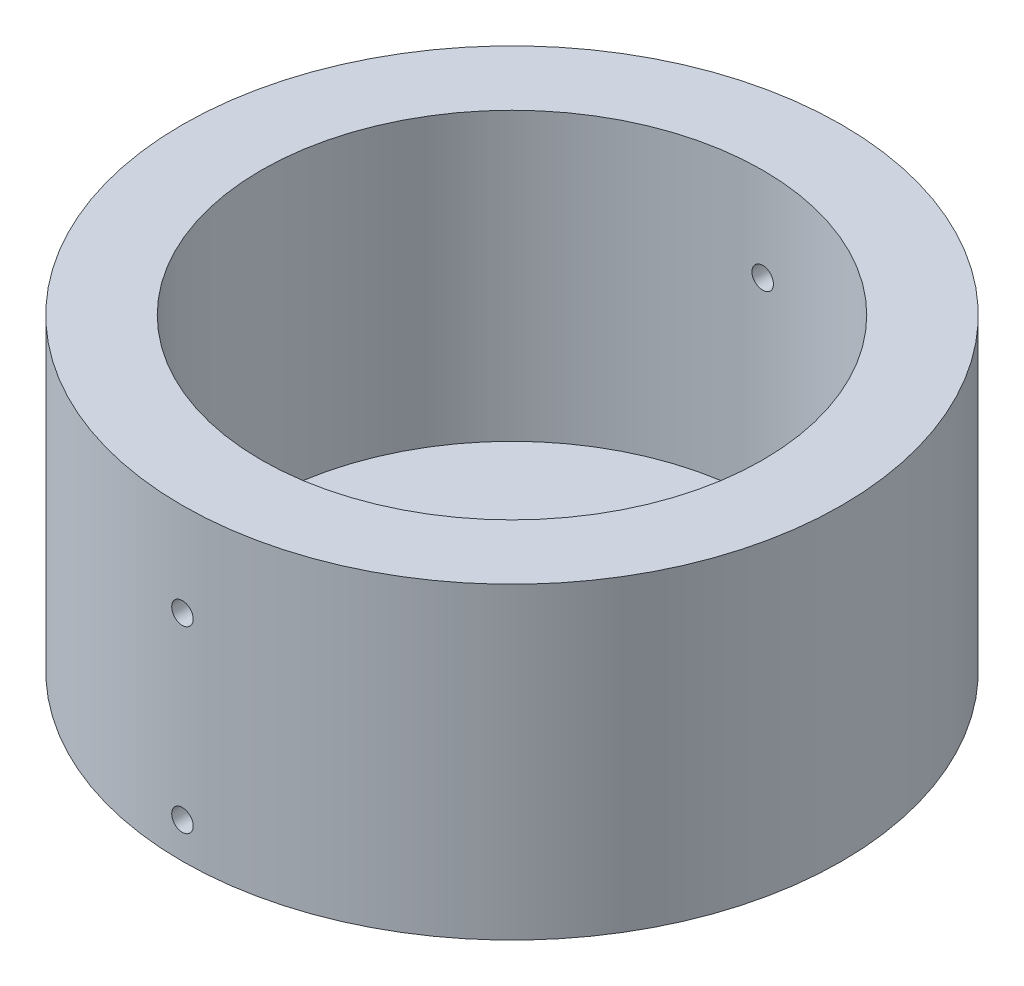
from build123d import *

# Parameters (mm, degrees)
SKETCH1_R               = 46
SKETCH1_R_2             = 3
SKETCH1_R_3             = 1.4
BOSS_EXTRUDE1_DEPTH     = 3
SKETCH6_R               = 1
CUT_EXTRUDE2_DEPTH      = 3
SKETCH7_R               = 46
SKETCH7_R_2             = 35
BOSS_EXTRUDE2_DEPTH     = 40
SKETCH8_R               = 1.5
CUT_EXTRUDE3_DEPTH      = 108
SKETCH9_R               = 1.5
CUT_EXTRUDE4_DEPTH      = 47.00000011
CUT_EXTRUDE4_DEPTH_BACK = 47.00000011


with BuildPart() as part:
    # Sketch1 → Boss-Extrude1 (new body)
    with BuildSketch(Plane(origin=(0, 0, 0), x_dir=(1, 0, 0), z_dir=(0, 1, 0))):
        Circle(SKETCH1_R)
        Circle(SKETCH1_R_2, mode=Mode.SUBTRACT)
        with Locations((0, 9.5)):
            Circle(SKETCH1_R_3, mode=Mode.SUBTRACT)
        with Locations((8.227241336, 4.75)):
            Circle(SKETCH1_R_3, mode=Mode.SUBTRACT)
        with Locations((8.227241336, -4.75)):
            Circle(SKETCH1_R_3, mode=Mode.SUBTRACT)
        with Locations((0, -9.5)):
            Circle(SKETCH1_R_3, mode=Mode.SUBTRACT)
        with Locations((-8.227241336, -4.75)):
            Circle(SKETCH1_R_3, mode=Mode.SUBTRACT)
        with Locations((-8.227241336, 4.75)):
            Circle(SKETCH1_R_3, mode=Mode.SUBTRACT)
    extrude(amount=BOSS_EXTRUDE1_DEPTH)

    # Sketch6 → Cut-Extrude2 (cut)
    with BuildSketch(Plane.XY.offset(-46)):
        with Locations((0, 1.5)):
            Circle(SKETCH6_R)
    extrude(amount=CUT_EXTRUDE2_DEPTH, mode=Mode.SUBTRACT)

    # Sketch7 → Boss-Extrude2 (add)
    with BuildSketch(Plane(origin=(0, 3, 0), x_dir=(1, 0, 0), z_dir=(0, 1, 0))):
        Circle(SKETCH7_R)
        Circle(SKETCH7_R_2, mode=Mode.SUBTRACT)
    extrude(amount=BOSS_EXTRUDE2_DEPTH)

    # Sketch8 → Cut-Extrude3 (cut)
    with BuildSketch(Plane.XY.offset(46)):
        with Locations((0, 30)):
            Circle(SKETCH8_R)
    extrude(amount=-CUT_EXTRUDE3_DEPTH, mode=Mode.SUBTRACT)

    # Sketch9 → Cut-Extrude4 (cut, two sides)
    with BuildSketch(Plane.XY) as cut_extrude4_sk:
        with Locations((0, 5)):
            Circle(SKETCH9_R)
    extrude(amount=CUT_EXTRUDE4_DEPTH, mode=Mode.SUBTRACT)
    extrude(cut_extrude4_sk.sketch, amount=-CUT_EXTRUDE4_DEPTH_BACK, mode=Mode.SUBTRACT)


solid = part.part
